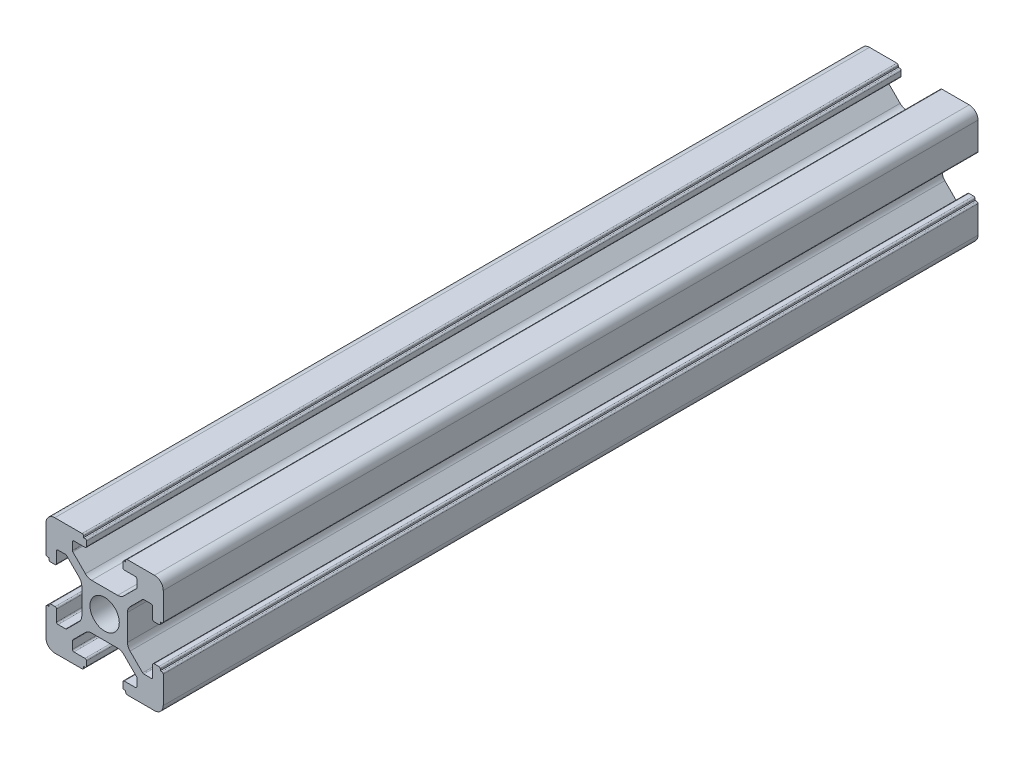
from build123d import *

# Parameters (mm, degrees)
SKETCH_1_R      = 2.5
EXTRUDE_1_DEPTH = 139


with BuildPart() as part:
    # 草图1 → 凸台-拉伸1 (new body)
    with BuildSketch(Plane.XY):
        with BuildLine():
            Line((-8.502261885, -10.002261885), (-3.85, -10.002261885))
            ThreePointArc((-3.85, -10.002261885), (-3.673223305, -9.929038581), (-3.6, -9.752261885))
            Line((-3.6, -9.752261885), (-3.6, -9.502261885))
            Line((-3.6, -9.502261885), (-3.35, -9.502261885))
            ThreePointArc((-3.35, -9.502261885), (-3.173223305, -9.429038581), (-3.1, -9.252261885))
            Line((-3.1, -9.252261885), (-3.1, -8.45))
            ThreePointArc((-3.1, -8.45), (-3.173223305, -8.273223305), (-3.35, -8.2))
            Line((-3.35, -8.2), (-5.25, -8.2))
            ThreePointArc((-5.25, -8.2), (-5.426776695, -8.126776695), (-5.5, -7.95))
            Line((-5.5, -7.95), (-5.5, -6.664213562))
            ThreePointArc((-5.5, -6.664213562), (-5.480969883, -6.568542704), (-5.426776695, -6.487436867))
            Line((-5.426776695, -6.487436867), (-3.278679656, -4.339339828))
            ThreePointArc((-3.278679656, -4.339339828), (-2.792044633, -4.014180701), (-2.218019485, -3.9))
            Line((-2.218019485, -3.9), (2.218019485, -3.9))
            ThreePointArc((2.218019485, -3.9), (2.792044633, -4.014180701), (3.278679656, -4.339339828))
            Line((3.278679656, -4.339339828), (5.426776695, -6.487436867))
            ThreePointArc((5.426776695, -6.487436867), (5.480969883, -6.568542704), (5.5, -6.664213562))
            Line((5.5, -6.664213562), (5.5, -7.95))
            ThreePointArc((5.5, -7.95), (5.426776695, -8.126776695), (5.25, -8.2))
            Line((5.25, -8.2), (3.35, -8.2))
            ThreePointArc((3.35, -8.2), (3.173223305, -8.273223305), (3.1, -8.45))
            Line((3.1, -8.45), (3.1, -9.252261885))
            ThreePointArc((3.1, -9.252261885), (3.173223305, -9.429038581), (3.35, -9.502261885))
            Line((3.35, -9.502261885), (3.6, -9.502261885))
            Line((3.6, -9.502261885), (3.6, -9.752261885))
            ThreePointArc((3.6, -9.752261885), (3.673223305, -9.929038581), (3.85, -10.002261885))
            Line((3.85, -10.002261885), (8.502261885, -10.002261885))
            ThreePointArc((8.502261885, -10.002261885), (9.562922057, -9.562922057), (10.002261885, -8.502261885))
            Line((10.002261885, -8.502261885), (10.002261885, -3.85))
            ThreePointArc((10.002261885, -3.85), (9.929038581, -3.673223305), (9.752261885, -3.6))
            Line((9.752261885, -3.6), (9.502261885, -3.6))
            Line((9.502261885, -3.6), (9.502261885, -3.35))
            ThreePointArc((9.502261885, -3.35), (9.429038581, -3.173223305), (9.252261885, -3.1))
            Line((9.252261885, -3.1), (8.45, -3.1))
            ThreePointArc((8.45, -3.1), (8.273223305, -3.173223305), (8.2, -3.35))
            Line((8.2, -3.35), (8.2, -5.25))
            ThreePointArc((8.2, -5.25), (8.126776695, -5.426776695), (7.95, -5.5))
            Line((7.95, -5.5), (6.664213562, -5.5))
            ThreePointArc((6.664213562, -5.5), (6.568542704, -5.480969883), (6.487436867, -5.426776695))
            Line((6.487436867, -5.426776695), (4.339339828, -3.278679656))
            ThreePointArc((4.339339828, -3.278679656), (4.014180701, -2.792044633), (3.9, -2.218019485))
            Line((3.9, -2.218019485), (3.9, 2.218019485))
            ThreePointArc((3.9, 2.218019485), (4.014180701, 2.792044633), (4.339339828, 3.278679656))
            Line((4.339339828, 3.278679656), (6.487436867, 5.426776695))
            ThreePointArc((6.487436867, 5.426776695), (6.568542704, 5.480969883), (6.664213562, 5.5))
            Line((6.664213562, 5.5), (7.95, 5.5))
            ThreePointArc((7.95, 5.5), (8.126776695, 5.426776695), (8.2, 5.25))
            Line((8.2, 5.25), (8.2, 3.35))
            ThreePointArc((8.2, 3.35), (8.273223305, 3.173223305), (8.45, 3.1))
            Line((8.45, 3.1), (9.252261885, 3.1))
            ThreePointArc((9.252261885, 3.1), (9.429038581, 3.173223305), (9.502261885, 3.35))
            Line((9.502261885, 3.35), (9.502261885, 3.6))
            Line((9.502261885, 3.6), (9.752261885, 3.6))
            ThreePointArc((9.752261885, 3.6), (9.929038581, 3.673223305), (10.002261885, 3.85))
            Line((10.002261885, 3.85), (10.002261885, 8.502261885))
            ThreePointArc((10.002261885, 8.502261885), (9.562922057, 9.562922057), (8.502261885, 10.002261885))
            Line((8.502261885, 10.002261885), (3.85, 10.002261885))
            ThreePointArc((3.85, 10.002261885), (3.673223305, 9.929038581), (3.6, 9.752261885))
            Line((3.6, 9.752261885), (3.6, 9.502261885))
            Line((3.6, 9.502261885), (3.35, 9.502261885))
            ThreePointArc((3.35, 9.502261885), (3.173223305, 9.429038581), (3.1, 9.252261885))
            Line((3.1, 9.252261885), (3.1, 8.45))
            ThreePointArc((3.1, 8.45), (3.173223305, 8.273223305), (3.35, 8.2))
            Line((3.35, 8.2), (5.25, 8.2))
            ThreePointArc((5.25, 8.2), (5.426776695, 8.126776695), (5.5, 7.95))
            Line((5.5, 7.95), (5.5, 6.664213562))
            ThreePointArc((5.5, 6.664213562), (5.480969883, 6.568542704), (5.426776695, 6.487436867))
            Line((5.426776695, 6.487436867), (3.278679656, 4.339339828))
            ThreePointArc((3.278679656, 4.339339828), (2.792044633, 4.014180701), (2.218019485, 3.9))
            Line((2.218019485, 3.9), (-2.218019485, 3.9))
            ThreePointArc((-2.218019485, 3.9), (-2.792044633, 4.014180701), (-3.278679656, 4.339339828))
            Line((-3.278679656, 4.339339828), (-5.426776695, 6.487436867))
            ThreePointArc((-5.426776695, 6.487436867), (-5.480969883, 6.568542704), (-5.5, 6.664213562))
            Line((-5.5, 6.664213562), (-5.5, 7.95))
            ThreePointArc((-5.5, 7.95), (-5.426776695, 8.126776695), (-5.25, 8.2))
            Line((-5.25, 8.2), (-3.35, 8.2))
            ThreePointArc((-3.35, 8.2), (-3.173223305, 8.273223305), (-3.1, 8.45))
            Line((-3.1, 8.45), (-3.1, 9.252261885))
            ThreePointArc((-3.1, 9.252261885), (-3.173223305, 9.429038581), (-3.35, 9.502261885))
            Line((-3.35, 9.502261885), (-3.6, 9.502261885))
            Line((-3.6, 9.502261885), (-3.6, 9.752261885))
            ThreePointArc((-3.6, 9.752261885), (-3.673223305, 9.929038581), (-3.85, 10.002261885))
            Line((-3.85, 10.002261885), (-8.502261885, 10.002261885))
            ThreePointArc((-8.502261885, 10.002261885), (-9.562922057, 9.562922057), (-10.002261885, 8.502261885))
            Line((-10.002261885, 8.502261885), (-10.002261885, 3.85))
            ThreePointArc((-10.002261885, 3.85), (-9.929038581, 3.673223305), (-9.752261885, 3.6))
            Line((-9.752261885, 3.6), (-9.502261885, 3.6))
            Line((-9.502261885, 3.6), (-9.502261885, 3.35))
            ThreePointArc((-9.502261885, 3.35), (-9.429038581, 3.173223305), (-9.252261885, 3.1))
            Line((-9.252261885, 3.1), (-8.45, 3.1))
            ThreePointArc((-8.45, 3.1), (-8.273223305, 3.173223305), (-8.2, 3.35))
            Line((-8.2, 3.35), (-8.2, 5.25))
            ThreePointArc((-8.2, 5.25), (-8.126776695, 5.426776695), (-7.95, 5.5))
            Line((-7.95, 5.5), (-6.664213562, 5.5))
            ThreePointArc((-6.664213562, 5.5), (-6.568542704, 5.480969883), (-6.487436867, 5.426776695))
            Line((-6.487436867, 5.426776695), (-4.339339828, 3.278679656))
            ThreePointArc((-4.339339828, 3.278679656), (-4.014180701, 2.792044633), (-3.9, 2.218019485))
            Line((-3.9, 2.218019485), (-3.9, -2.218019485))
            ThreePointArc((-3.9, -2.218019485), (-4.014180701, -2.792044633), (-4.339339828, -3.278679656))
            Line((-4.339339828, -3.278679656), (-6.487436867, -5.426776695))
            ThreePointArc((-6.487436867, -5.426776695), (-6.568542704, -5.480969883), (-6.664213562, -5.5))
            Line((-6.664213562, -5.5), (-7.95, -5.5))
            ThreePointArc((-7.95, -5.5), (-8.126776695, -5.426776695), (-8.2, -5.25))
            Line((-8.2, -5.25), (-8.2, -3.35))
            ThreePointArc((-8.2, -3.35), (-8.273223305, -3.173223305), (-8.45, -3.1))
            Line((-8.45, -3.1), (-9.252261885, -3.1))
            ThreePointArc((-9.252261885, -3.1), (-9.429038581, -3.173223305), (-9.502261885, -3.35))
            Line((-9.502261885, -3.35), (-9.502261885, -3.6))
            Line((-9.502261885, -3.6), (-9.752261885, -3.6))
            ThreePointArc((-9.752261885, -3.6), (-9.929038581, -3.673223305), (-10.002261885, -3.85))
            Line((-10.002261885, -3.85), (-10.002261885, -8.502261885))
            ThreePointArc((-10.002261885, -8.502261885), (-9.562922057, -9.562922057), (-8.502261885, -10.002261885))
        make_face()
        Circle(SKETCH_1_R, mode=Mode.SUBTRACT)
    extrude(amount=EXTRUDE_1_DEPTH)


solid = part.part
